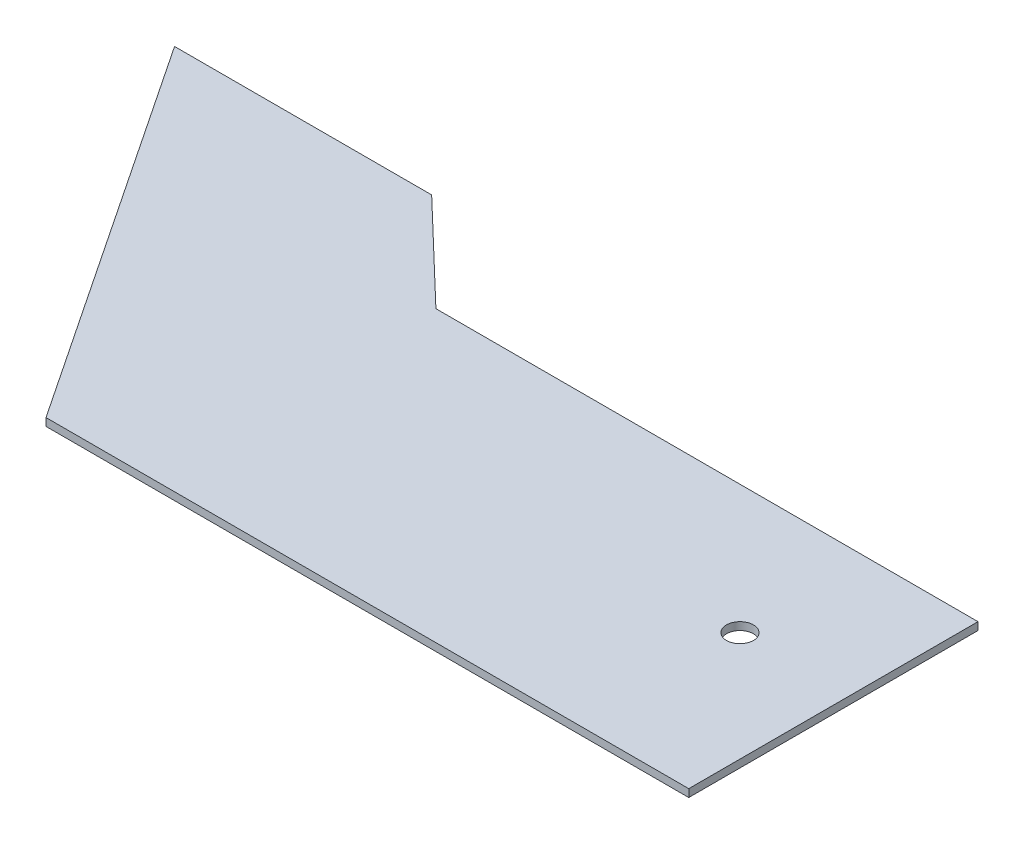
from build123d import *

# Parameters (mm, degrees)
SKETCH2_R           = 2.1
BOSS_EXTRUDE1_DEPTH = 1.2
CUT_EXTRUDE1_DEPTH  = 1.5
SKETCH4_R           = 2.1
BOSS_EXTRUDE3_DEPTH = 1.2
CUT_EXTRUDE2_DEPTH  = 1.5


with BuildPart() as part:
    # Sketch2 → Boss-Extrude1 (new body)
    with BuildSketch(Plane(origin=(0, 0, 0), x_dir=(1, 0, 0), z_dir=(0, 1, 0))):
        Polygon((39.4127274, 50.640295112), (39.4127274, 0.640295112), (-45.5872726, 0.640295112), (-80.5872726, 50.640295112), align=None)
        with Locations((22.381300815, 25.64100497)):
            Circle(SKETCH2_R, mode=Mode.SUBTRACT)
    extrude(amount=BOSS_EXTRUDE1_DEPTH)

    # Sketch3 → Cut-Extrude1 (cut)
    with BuildSketch(Plane(origin=(0, 1.2, 0), x_dir=(1, 0, 0), z_dir=(0, 1, 0))):
        Polygon((39.4127274, 40.640295112), (-30.5872726, 40.640295112), (-50.5872726, 50.640295112), (39.4127274, 50.640295112), align=None)
    extrude(amount=-CUT_EXTRUDE1_DEPTH, mode=Mode.SUBTRACT)

    # Sketch4 → Boss-Extrude3 (add)
    with BuildSketch(Plane(origin=(0, 1.2, 0), x_dir=(1, 0, 0), z_dir=(0, 1, 0))):
        Polygon((39.4127274, 0.640295112), (-60.5872726, 0.640295112), (-100.5872726, 60.640295112), (-60.5872726, 60.640295112), (-44.926762529, 45.640295112), (39.4127274, 45.640295112), align=None)
        with Locations((22.381300815, 25.64100497)):
            Circle(SKETCH4_R, mode=Mode.SUBTRACT)
    extrude(amount=-BOSS_EXTRUDE3_DEPTH)

    # Sketch6 → Cut-Extrude2 (cut)
    with BuildSketch(Plane(origin=(0, 1.2, 0), x_dir=(1, 0, 0), z_dir=(0, 1, 0))):
        Polygon((-40.5872726, 45.640295112), (-44.926762529, 45.640295112), (-49.666026343, 50.179671984), align=None)
    extrude(amount=-CUT_EXTRUDE2_DEPTH, mode=Mode.SUBTRACT)


solid = part.part
